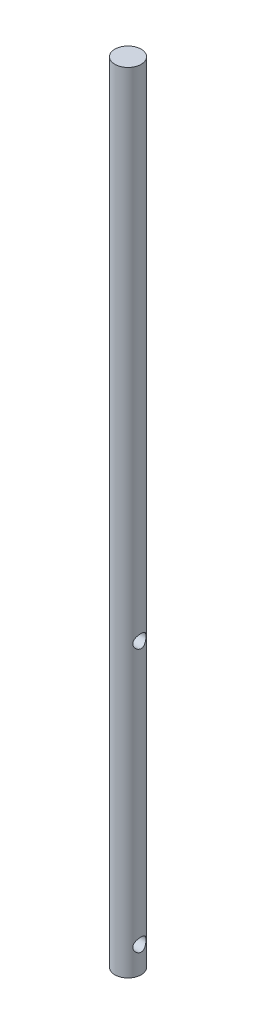
from build123d import *

# Parameters (mm, degrees)
SKETCH_1_W               = 5
SKETCH_1_H               = 300
SKETCH_2_R               = 2.5
CUT_EXTRUDE_1_DEPTH      = 6
CUT_EXTRUDE_1_DEPTH_BACK = 6


with BuildPart() as part:
    # Эскиз1 → Повернуть1 (revolve)
    with BuildSketch(Plane(origin=(0, 0, 0), x_dir=(0, 0, -1), z_dir=(1, 0, 0))):
        with Locations((2.5, 150)):
            Rectangle(SKETCH_1_W, SKETCH_1_H)
    revolve(axis=Axis((0, 0, 0), (0, 1, 0)))

    # Эскиз2 → Вырез-Вытянуть1 (cut, two sides)
    with BuildSketch(Plane(origin=(0, 0, 0), x_dir=(0, 0, -1), z_dir=(1, 0, 0))) as cut_extrude_1_sk:
        with Locations((0, 10)):
            Circle(SKETCH_2_R)
        with Locations((0, 110)):
            Circle(SKETCH_2_R)
    extrude(amount=CUT_EXTRUDE_1_DEPTH, mode=Mode.SUBTRACT)
    extrude(cut_extrude_1_sk.sketch, amount=-CUT_EXTRUDE_1_DEPTH_BACK, mode=Mode.SUBTRACT)


solid = part.part
